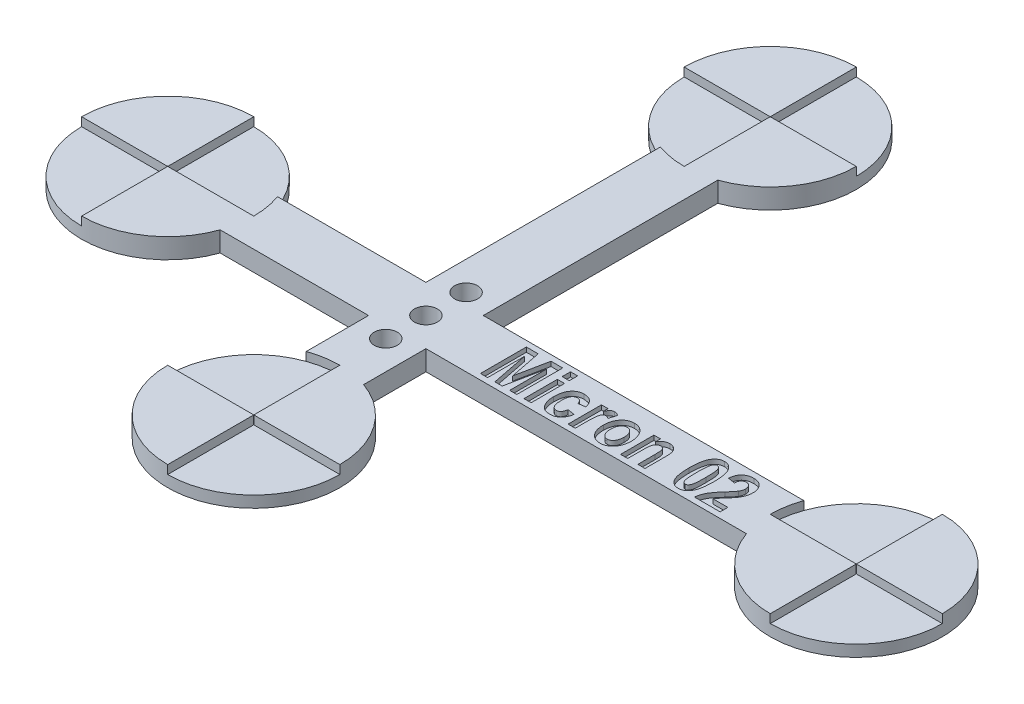
from build123d import *

# Parameters (mm, degrees)
BOSS_EXTRUDE1_DEPTH = 3.5
CUT_EXTRUDE1_DEPTH  = 1.5
SKETCH3_W           = 1.246753247
SKETCH3_H           = 1.454545455
SKETCH3_H_2         = 5.818181818
CUT_EXTRUDE2_DEPTH  = 0.8
SKETCH4_R           = 2
CUT_EXTRUDE3_DEPTH  = 4.5


with BuildPart() as part:
    # Sketch1 → Boss-Extrude1 (new body)
    with BuildSketch(Plane(origin=(0, 0, 0), x_dir=(1, 0, 0), z_dir=(0, 1, 0))):
        with BuildLine():
            Line((40, 45.857864376), (40, 5))
            Line((40, 5), (14.142135624, 5))
            ThreePointArc((14.142135624, 5), (-15, 0), (14.142135624, -5))
            Line((14.142135624, -5), (40, -5))
            Line((40, -5), (40, -15.857864376))
            ThreePointArc((40, -15.857864376), (45, -45), (50, -15.857864376))
            Line((50, -15.857864376), (50, -5))
            Line((50, -5), (105.857864376, -5))
            ThreePointArc((105.857864376, -5), (135, 0), (105.857864376, 5))
            Line((105.857864376, 5), (50, 5))
            Line((50, 5), (50, 45.857864376))
            ThreePointArc((50, 45.857864376), (45, 75), (40, 45.857864376))
        make_face()
    extrude(amount=BOSS_EXTRUDE1_DEPTH)

    # Sketch2 → Cut-Extrude1 (cut)
    with BuildSketch(Plane(origin=(0, 3.5, 0), x_dir=(1, 0, 0), z_dir=(0, 1, 0))):
        with BuildLine():
            Line((-15, 0), (-0.05, 0))
            ThreePointArc((-0.05, 0), (-0.035355339, 0.035355339), (0, 0.05))
            Line((0, 0.05), (0, 15))
            ThreePointArc((0, 15), (10.606601718, 10.606601718), (15, 0))
            Line((15, 0), (0.05, 0))
            ThreePointArc((0.05, 0), (0.035355339, -0.035355339), (0, -0.05))
            Line((0, -0.05), (0, -15))
            ThreePointArc((0, -15), (-10.606601718, -10.606601718), (-15, 0))
        make_face()
        with BuildLine():
            Line((45, 75), (45, 60.05))
            ThreePointArc((45, 60.05), (44.964644661, 60.035355339), (44.95, 60))
            Line((44.95, 60), (30, 60))
            ThreePointArc((30, 60), (34.393398282, 49.393398282), (45, 45))
            Line((45, 45), (45, 59.95))
            ThreePointArc((45, 59.95), (45.035355339, 59.964644661), (45.05, 60))
            Line((45.05, 60), (60, 60))
            ThreePointArc((60, 60), (55.606601718, 70.606601718), (45, 75))
        make_face()
        with BuildLine():
            Line((120, 15), (120, 0.05))
            ThreePointArc((120, 0.05), (120.035355339, 0.035355339), (120.05, 0))
            Line((120.05, 0), (135, 0))
            ThreePointArc((135, 0), (130.606601718, -10.606601718), (120, -15))
            Line((120, -15), (120, -0.05))
            ThreePointArc((120, -0.05), (119.964644661, -0.035355339), (119.95, 0))
            Line((119.95, 0), (105, 0))
            ThreePointArc((105, 0), (109.393398282, 10.606601718), (120, 15))
        make_face()
        with BuildLine():
            Line((30, -30), (44.95, -30))
            ThreePointArc((44.95, -30), (44.964644661, -30.035355339), (45, -30.05))
            Line((45, -30.05), (45, -45))
            ThreePointArc((45, -45), (55.606601718, -40.606601718), (60, -30))
            Line((60, -30), (45.05, -30))
            ThreePointArc((45.05, -30), (45.035355339, -29.964644661), (45, -29.95))
            Line((45, -29.95), (45, -15))
            ThreePointArc((45, -15), (34.393398282, -19.393398282), (30, -30))
        make_face()
    extrude(amount=-CUT_EXTRUDE1_DEPTH, mode=Mode.SUBTRACT)

    # Sketch3 → Cut-Extrude2 (cut)
    with BuildSketch(Plane(origin=(0, 3.5, 0), x_dir=(1, 0, 0), z_dir=(0, 1, 0))):
        Polygon((58.50036076, -4), (58.50036076, 4), (60.563672448, 4), (61.669191928, -1.561688312), (62.795815305, 4), (64.838023097, 4), (64.838023097, -4), (63.59126985, -4), (63.59126985, 2.400974026), (62.290945175, -4), (61.023088032, -4), (59.747114006, 2.400974026), (59.747114006, -4), align=None)
        with Locations((66.708152968, 3.376623377)):
            Rectangle(SKETCH3_W, SKETCH3_H)
        with Locations((66.708152968, -1.090909091)):
            Rectangle(SKETCH3_W, SKETCH3_H_2)
        with BuildLine():
            Line((72.734126993, 0.155844156), (71.487373747, -0.051948052))
            add(Edge.make_bspline(
                [(71.487373747, -0.051948052), (71.475238631, 0.013492139), (71.452160271, 0.137945199), (71.389179941, 0.307989308), (71.312160634, 0.454611766), (71.213055442, 0.573886506), (71.095416345, 0.667213464), (70.958609537, 0.733166985), (70.803936467, 0.772456922), (70.694860886, 0.776912369), (70.638347773, 0.779220779)],
                knots=[0, 0, 0, 0, 0.000199325, 0.000379073, 0.0005418, 0.000693948, 0.000840745, 0.000988855, 0.001146348, 0.001315678, 0.001315678, 0.001315678, 0.001315678], degree=3))
            add(Edge.make_bspline(
                [(70.638347773, 0.779220779), (70.600905429, 0.778062939), (70.527122523, 0.775781331), (70.420010496, 0.755102855), (70.317553938, 0.725549098), (70.222958212, 0.677663569), (70.130758823, 0.622007918), (70.046957124, 0.549315551), (69.968136169, 0.465515202), (69.894709448, 0.369037743), (69.827095322, 0.257785931), (69.770603047, 0.128257783), (69.725083376, -0.018687378), (69.68335517, -0.181979253), (69.653655963, -0.363419746), (69.633180941, -0.562384664), (69.620101663, -0.77850796), (69.618220871, -0.928551854), (69.617243876, -1.006493506)],
                knots=[0, 0, 0, 0, 0.000112201, 0.0002211, 0.00032637, 0.000430923, 0.000538128, 0.000648708, 0.000762403, 0.000882861, 0.001011764, 0.001152033, 0.001305535, 0.001472868, 0.001657284, 0.001856457, 0.002072757, 0.002306574, 0.002306574, 0.002306574, 0.002306574], degree=3))
            add(Edge.make_bspline(
                [(69.617243876, -1.006493506), (69.618261217, -1.092546265), (69.620213954, -1.257720471), (69.632711779, -1.496116795), (69.65538517, -1.714396148), (69.685469478, -1.914085761), (69.725675307, -2.093641007), (69.774055334, -2.254680712), (69.831596703, -2.395907747), (69.899086485, -2.518208897), (69.974173657, -2.623094471), (70.056196277, -2.712538943), (70.142228328, -2.791034021), (70.2374127, -2.851962864), (70.336627186, -2.901864568), (70.442857496, -2.935934853), (70.55464497, -2.95784839), (70.631749283, -2.959966029), (70.670815305, -2.961038961)],
                knots=[0, 0, 0, 0, 0.000258163, 0.000495531, 0.000715862, 0.000916302, 0.00110101, 0.001267389, 0.001420236, 0.001557572, 0.001685521, 0.001806187, 0.001921184, 0.002033748, 0.002144102, 0.002253448, 0.002367432, 0.002484495, 0.002484495, 0.002484495, 0.002484495], degree=3))
            add(Edge.make_bspline(
                [(70.670815305, -2.961038961), (70.72855094, -2.958115137), (70.840148837, -2.952463643), (70.998917272, -2.902884688), (71.141871425, -2.82385793), (71.244914469, -2.730611667), (71.318466989, -2.639969699), (71.370108431, -2.557981246), (71.418545215, -2.464077917), (71.462084604, -2.358060987), (71.501266248, -2.240396767), (71.534349316, -2.110465037), (71.565645908, -1.968673701), (71.582502685, -1.869672225), (71.59126985, -1.818181818)],
                knots=[0, 0, 0, 0, 0.000172842, 0.000334088, 0.000493972, 0.000659525, 0.000747247, 0.000843616, 0.000949622, 0.001063883, 0.001187088, 0.001321358, 0.001465921, 0.001622591, 0.001622591, 0.001622591, 0.001622591], degree=3))
            Line((71.59126985, -1.818181818), (72.838023097, -2.025974026))
            add(Edge.make_bspline(
                [(72.838023097, -2.025974026), (72.821015846, -2.110033143), (72.787894315, -2.273737832), (72.725282574, -2.51019173), (72.648292222, -2.729306841), (72.562922764, -2.933353422), (72.465367894, -3.120817392), (72.35648555, -3.292169834), (72.236010198, -3.447294215), (72.103969601, -3.586117196), (71.960430352, -3.708703947), (71.805564143, -3.814231607), (71.640086257, -3.904896068), (71.462835354, -3.977226655), (71.274845438, -4.034537616), (71.075882267, -4.074640125), (70.865713047, -4.099528833), (70.721752457, -4.102417816), (70.648088032, -4.103896104)],
                knots=[0, 0, 0, 0, 0.000257263, 0.000501018, 0.000733076, 0.000953485, 0.001164055, 0.001366255, 0.001561742, 0.001752349, 0.001940051, 0.002126916, 0.002313611, 0.002505046, 0.002700189, 0.002902356, 0.003113183, 0.003334111, 0.003334111, 0.003334111, 0.003334111], degree=3))
            add(Edge.make_bspline(
                [(70.648088032, -4.103896104), (70.554819841, -4.101887492), (70.37321271, -4.097976423), (70.110471697, -4.053593587), (69.864673186, -3.987367001), (69.639207309, -3.888476021), (69.431834059, -3.764176577), (69.243759839, -3.611361294), (69.073517705, -3.431602628), (68.925921273, -3.224317401), (68.795814013, -2.999463478), (68.681997355, -2.762165056), (68.585965745, -2.513438303), (68.506034653, -2.254410985), (68.446476255, -1.98270864), (68.403410095, -1.700737492), (68.374039392, -1.407542533), (68.371686907, -1.208406699), (68.37049063, -1.107142857)],
                knots=[0, 0, 0, 0, 0.000279523, 0.000544272, 0.000797144, 0.001041429, 0.001280302, 0.001520398, 0.001766145, 0.002020725, 0.002281892, 0.002544739, 0.002809429, 0.003081077, 0.00335717, 0.003643018, 0.003936526, 0.004240206, 0.004240206, 0.004240206, 0.004240206], degree=3))
            add(Edge.make_bspline(
                [(68.37049063, -1.107142857), (68.372239743, -0.987488549), (68.375640625, -0.75483916), (68.405336818, -0.417027711), (68.452726945, -0.100401237), (68.522926455, 0.193547978), (68.609847208, 0.466113039), (68.716501303, 0.716580192), (68.846096582, 0.943069469), (68.991820845, 1.149170928), (69.156114523, 1.330213011), (69.331961705, 1.489088097), (69.520060194, 1.623763244), (69.721234776, 1.733258723), (69.935011157, 1.818073271), (70.160732658, 1.877319248), (70.397782122, 1.916873853), (70.560259998, 1.920318934), (70.643217902, 1.922077922)],
                knots=[0, 0, 0, 0, 0.000358898, 0.000697823, 0.001016501, 0.00131851, 0.001603435, 0.001873935, 0.002133483, 0.002384849, 0.002629678, 0.002865336, 0.003094623, 0.003322001, 0.003550805, 0.003782743, 0.004021075, 0.004269712, 0.004269712, 0.004269712, 0.004269712], degree=3))
            add(Edge.make_bspline(
                [(70.643217902, 1.922077922), (70.71035858, 1.920846466), (70.841687336, 1.918437708), (71.034520622, 1.899106266), (71.217142954, 1.864581364), (71.391368457, 1.819675788), (71.554972261, 1.759740953), (71.709026878, 1.685791916), (71.853826329, 1.599814288), (71.98980103, 1.500415487), (72.115185036, 1.385394066), (72.233134509, 1.256930605), (72.340019014, 1.110862201), (72.439342218, 0.950708523), (72.526615855, 0.773374249), (72.606095879, 0.582082787), (72.676087051, 0.374743093), (72.714406275, 0.230221286), (72.734126993, 0.155844156)],
                knots=[0, 0, 0, 0, 0.000201403, 0.00039395, 0.000580532, 0.000758512, 0.000933129, 0.001102311, 0.00127047, 0.001437685, 0.001606618, 0.001780137, 0.00196001, 0.002148783, 0.002344802, 0.00255222, 0.002769885, 0.003000685, 0.003000685, 0.003000685, 0.003000685], degree=3))
        make_face()
        with BuildLine():
            Line((75.019841279, -4), (73.773088032, -4))
            Line((73.773088032, -4), (73.773088032, 1.818181818))
            Line((73.773088032, 1.818181818), (74.915945175, 1.818181818))
            Line((74.915945175, 1.818181818), (74.915945175, 0.991883117))
            add(Edge.make_bspline(
                [(74.915945175, 0.991883117), (74.940159399, 1.037952881), (74.986797897, 1.126686869), (75.05617644, 1.253336089), (75.123683954, 1.367923953), (75.192594719, 1.467096929), (75.254997633, 1.556811947), (75.319023898, 1.631359029), (75.379881779, 1.694731582), (75.457465413, 1.762170073), (75.560087337, 1.826053482), (75.691232303, 1.882473547), (75.832643067, 1.915363311), (75.929848968, 1.919815142), (75.979256863, 1.922077922)],
                knots=[0, 0, 0, 0, 0.000156131, 0.000300721, 0.000433243, 0.000554812, 0.000662946, 0.000760848, 0.000849244, 0.000926367, 0.001068679, 0.001209792, 0.001353128, 0.001501291, 0.001501291, 0.001501291, 0.001501291], degree=3))
            add(Edge.make_bspline(
                [(75.979256863, 1.922077922), (76.049468143, 1.91886318), (76.189930484, 1.912431875), (76.396264458, 1.852623193), (76.598585759, 1.762131289), (76.72239596, 1.675863479), (76.786075045, 1.631493506)],
                knots=[0, 0, 0, 0, 0.000210176, 0.00042047, 0.000639866, 0.000872208, 0.000872208, 0.000872208, 0.000872208], degree=3))
            Line((76.786075045, 1.631493506), (76.391594526, 0.319805195))
            add(Edge.make_bspline(
                [(76.391594526, 0.319805195), (76.343457298, 0.358255441), (76.252471756, 0.430931343), (76.106176233, 0.509110372), (75.96429064, 0.560954838), (75.869258342, 0.568020125), (75.823412708, 0.571428571)],
                knots=[0, 0, 0, 0, 0.000184416, 0.00034857, 0.000495904, 0.00063323, 0.00063323, 0.00063323, 0.00063323], degree=3))
            add(Edge.make_bspline(
                [(75.823412708, 0.571428571), (75.782505012, 0.569577552), (75.701066257, 0.565892554), (75.584319511, 0.525699903), (75.474380215, 0.46484784), (75.373247856, 0.375884101), (75.28120342, 0.255501948), (75.208770468, 0.094601523), (75.146148418, -0.102439271), (75.107437305, -0.295455124), (75.083085691, -0.477538767), (75.06505598, -0.645297865), (75.050951083, -0.839680763), (75.040281294, -1.060551746), (75.030100881, -1.307830134), (75.023930168, -1.582222395), (75.021131213, -1.883652001), (75.020282911, -2.093614232), (75.019841279, -2.202922078)],
                knots=[0, 0, 0, 0, 0.000122282, 0.000243439, 0.00036627, 0.000497452, 0.000644536, 0.000817347, 0.001023727, 0.001264102, 0.001406673, 0.001574831, 0.001770184, 0.001991255, 0.002238201, 0.002512628, 0.002814594, 0.00314252, 0.00314252, 0.00314252, 0.00314252], degree=3))
            Line((75.019841279, -2.202922078), (75.019841279, -4))
        make_face()
        with BuildLine():
            add(Edge.make_bspline(
                [(76.993867253, -1.00974026), (76.99773938, -0.871492577), (77.005358765, -0.599455473), (77.07087566, -0.202105645), (77.173904845, 0.177168447), (77.298261932, 0.475142281), (77.414852128, 0.700213025), (77.508933594, 0.858166819), (77.610211845, 1.0047968), (77.716400181, 1.140905493), (77.830224235, 1.265802708), (77.948905998, 1.380456268), (78.075551332, 1.483975824), (78.251872281, 1.606243165), (78.48640792, 1.734106031), (78.786697572, 1.843482079), (79.103960535, 1.910979968), (79.321452502, 1.918333961), (79.432178941, 1.922077922)],
                knots=[0, 0, 0, 0, 0.000414499, 0.00081563, 0.001204757, 0.001591247, 0.00178148, 0.00196495, 0.002142367, 0.002315787, 0.002482426, 0.002648908, 0.002810415, 0.002972534, 0.003292157, 0.00360852, 0.00392849, 0.004260331, 0.004260331, 0.004260331, 0.004260331], degree=3))
            add(Edge.make_bspline(
                [(79.432178941, 1.922077922), (79.524844362, 1.919080026), (79.706214487, 1.913212371), (79.970819979, 1.872921067), (80.219608224, 1.802229151), (80.453953528, 1.705294578), (80.670723745, 1.576365199), (80.874437856, 1.423442467), (81.059923504, 1.239208288), (81.228428557, 1.030627633), (81.37997441, 0.803981072), (81.513296238, 0.565748818), (81.625008798, 0.317712454), (81.719657136, 0.061815795), (81.787549524, -0.205805812), (81.840332848, -0.481537671), (81.871889339, -0.767122546), (81.87526987, -0.960420315), (81.876984136, -1.058441558)],
                knots=[0, 0, 0, 0, 0.000277982, 0.000544082, 0.000800519, 0.001052268, 0.001302568, 0.001555169, 0.001814604, 0.002084622, 0.002358372, 0.002631625, 0.002902613, 0.00317376, 0.003448993, 0.003729814, 0.004015574, 0.004309567, 0.004309567, 0.004309567, 0.004309567], degree=3))
            add(Edge.make_bspline(
                [(81.876984136, -1.058441558), (81.876227692, -1.131529258), (81.874729677, -1.276267575), (81.857345801, -1.490737935), (81.832372892, -1.700083082), (81.794451847, -1.904353031), (81.74632035, -2.102762528), (81.686787225, -2.295895078), (81.619804227, -2.484139081), (81.53955722, -2.665021822), (81.453170655, -2.838694854), (81.356567034, -3.000287959), (81.256676902, -3.152976813), (81.14667086, -3.291813358), (81.033747016, -3.423233057), (80.911462009, -3.541439921), (80.783056626, -3.649149424), (80.604551972, -3.775655653), (80.369934842, -3.906802618), (80.071483883, -4.020332864), (79.759616253, -4.091116904), (79.546182896, -4.0996153), (79.438672448, -4.103896104)],
                knots=[0, 0, 0, 0, 0.00021921, 0.00043411, 0.00064513, 0.000851458, 0.001056987, 0.001257262, 0.001457537, 0.001655994, 0.001850563, 0.002039049, 0.002220497, 0.002397475, 0.002570043, 0.002739947, 0.002907061, 0.003072374, 0.003395769, 0.003710226, 0.004027699, 0.00434993, 0.00434993, 0.00434993, 0.00434993], degree=3))
            add(Edge.make_bspline(
                [(79.438672448, -4.103896104), (79.352502729, -4.101341217), (79.183124459, -4.096319241), (78.934716636, -4.058456248), (78.698054839, -3.99479852), (78.472549003, -3.90676201), (78.258016744, -3.793542556), (78.054181778, -3.655526311), (77.864029071, -3.488983811), (77.683779026, -3.302138577), (77.520670531, -3.090331966), (77.380150134, -2.855461331), (77.258457363, -2.600481865), (77.162310721, -2.322961565), (77.085543251, -2.024985427), (77.033233234, -1.70496049), (77.000302919, -1.364326972), (76.996049016, -1.12994916), (76.993867253, -1.00974026)],
                knots=[0, 0, 0, 0, 0.000258443, 0.000508006, 0.000751761, 0.000992327, 0.001232686, 0.001478079, 0.001728994, 0.001989631, 0.002255885, 0.002529003, 0.002809298, 0.003101956, 0.003408675, 0.003731336, 0.004073787, 0.004434356, 0.004434356, 0.004434356, 0.004434356], degree=3))
        make_face()
        with BuildLine():
            add(Edge.make_bspline(
                [(78.2406205, -1.090909091), (78.241193573, -1.161301131), (78.242306492, -1.298003716), (78.261234707, -1.496347271), (78.288602558, -1.681695553), (78.324236438, -1.854514739), (78.376162408, -2.012893615), (78.434745234, -2.159458772), (78.506897923, -2.292206203), (78.589461187, -2.410648066), (78.680939517, -2.51464094), (78.776964817, -2.605361366), (78.875632321, -2.685555047), (78.982414792, -2.746314388), (79.091993225, -2.7960892), (79.205812587, -2.83181335), (79.324708332, -2.854023891), (79.405564639, -2.856089635), (79.446789331, -2.857142857)],
                knots=[0, 0, 0, 0, 0.000211095, 0.000409951, 0.000597062, 0.000773144, 0.000938458, 0.001096426, 0.001246068, 0.00139063, 0.001528684, 0.001660738, 0.001786746, 0.001908974, 0.002028146, 0.002147262, 0.002266036, 0.002389583, 0.002389583, 0.002389583, 0.002389583], degree=3))
            add(Edge.make_bspline(
                [(79.446789331, -2.857142857), (79.486930477, -2.856062286), (79.566168615, -2.853929251), (79.682924616, -2.831796204), (79.794636913, -2.796265769), (79.902095046, -2.746661195), (80.004819397, -2.682536946), (80.103605063, -2.604942025), (80.196824143, -2.512150646), (80.285902055, -2.407554507), (80.367452538, -2.288190002), (80.439332996, -2.15529938), (80.496230932, -2.007207398), (80.548090785, -1.84851973), (80.583928744, -1.674677795), (80.611733592, -1.488309881), (80.627963108, -1.288165559), (80.629460002, -1.150461681), (80.630230889, -1.079545455)],
                knots=[0, 0, 0, 0, 0.000120305, 0.000237481, 0.00035505, 0.000471266, 0.000591549, 0.000717557, 0.000847275, 0.000985501, 0.00112914, 0.00128021, 0.001437568, 0.001604429, 0.001780511, 0.001969228, 0.002169562, 0.00238228, 0.00238228, 0.00238228, 0.00238228], degree=3))
            add(Edge.make_bspline(
                [(80.630230889, -1.079545455), (80.629657673, -1.010234819), (80.628544962, -0.875690947), (80.609642621, -0.680588811), (80.582133444, -0.497953131), (80.546465486, -0.327351399), (80.49521573, -0.170068224), (80.433692654, -0.025632812), (80.362554163, 0.1072581), (80.279265313, 0.225728002), (80.188791642, 0.330494971), (80.093903874, 0.422586459), (79.99490702, 0.50126615), (79.890651683, 0.564846212), (79.782053107, 0.614109415), (79.669460084, 0.65026489), (79.551531628, 0.672061169), (79.471231571, 0.67422738), (79.430555565, 0.675324675)],
                knots=[0, 0, 0, 0, 0.000207849, 0.000403471, 0.000587372, 0.000761868, 0.000925636, 0.001082735, 0.001232376, 0.001376939, 0.001516219, 0.001647099, 0.001773107, 0.001894774, 0.002012466, 0.002130035, 0.002248808, 0.002370734, 0.002370734, 0.002370734, 0.002370734], degree=3))
            add(Edge.make_bspline(
                [(79.430555565, 0.675324675), (79.390416835, 0.674238638), (79.311183466, 0.672094813), (79.194392368, 0.650041164), (79.082343389, 0.614060182), (78.973968514, 0.565297339), (78.870848855, 0.500737434), (78.772125734, 0.422584114), (78.677081903, 0.331022603), (78.588667404, 0.225050714), (78.504100416, 0.107532851), (78.436606876, -0.027537366), (78.372844625, -0.171655992), (78.32568136, -0.331268167), (78.285792867, -0.502358852), (78.261951191, -0.687847561), (78.242143614, -0.884859588), (78.241136929, -1.021045607), (78.2406205, -1.090909091)],
                knots=[0, 0, 0, 0, 0.000120305, 0.000237481, 0.00035505, 0.000472742, 0.000593025, 0.000719033, 0.000849914, 0.000988139, 0.001132702, 0.001283011, 0.00144011, 0.001604937, 0.00178137, 0.001966642, 0.002165497, 0.002374969, 0.002374969, 0.002374969, 0.002374969], degree=3))
        make_face(mode=Mode.SUBTRACT)
        with BuildLine():
            Line((87.175685435, -4), (85.928932188, -4))
            Line((85.928932188, -4), (85.928932188, -1.025974026))
            add(Edge.make_bspline(
                [(85.928932188, -1.025974026), (85.92854282, -0.954543529), (85.927799442, -0.818169062), (85.924356954, -0.622819841), (85.920247564, -0.445806445), (85.911867341, -0.287253276), (85.902241106, -0.147618119), (85.891650159, -0.026736408), (85.87710847, 0.075056785), (85.856368171, 0.184335425), (85.821004006, 0.301543782), (85.764596313, 0.426141455), (85.692774231, 0.534382367), (85.604019629, 0.62160385), (85.506619056, 0.69206755), (85.401915582, 0.743240838), (85.289966246, 0.77397023), (85.213215912, 0.777447079), (85.174062058, 0.779220779)],
                knots=[0, 0, 0, 0, 0.000214292, 0.000409124, 0.000586139, 0.000745437, 0.000885387, 0.001006053, 0.001109364, 0.001193733, 0.001339584, 0.001475415, 0.001602837, 0.00172681, 0.001846644, 0.001962086, 0.002074709, 0.002191998, 0.002191998, 0.002191998, 0.002191998], degree=3))
            add(Edge.make_bspline(
                [(85.174062058, 0.779220779), (85.123447016, 0.776869331), (85.023371597, 0.772220076), (84.878191919, 0.730407315), (84.739286208, 0.667322233), (84.612395844, 0.575023409), (84.495650377, 0.46328544), (84.398737064, 0.328262501), (84.317469986, 0.175298829), (84.268630692, 0.030618942), (84.236032455, -0.101357957), (84.218310317, -0.222713773), (84.199402097, -0.363228665), (84.188161741, -0.524290952), (84.175994029, -0.704955422), (84.168471275, -0.905793407), (84.163505023, -1.126597226), (84.162974738, -1.280299629), (84.162698422, -1.36038961)],
                knots=[0, 0, 0, 0, 0.000151532, 0.000299606, 0.000449951, 0.00060715, 0.000767873, 0.000932819, 0.001103467, 0.001285727, 0.00138928, 0.001510979, 0.001653337, 0.001814575, 0.001995128, 0.00219659, 0.002417423, 0.002657688, 0.002657688, 0.002657688, 0.002657688], degree=3))
            Line((84.162698422, -1.36038961), (84.162698422, -4))
            Line((84.162698422, -4), (82.915945175, -4))
            Line((82.915945175, -4), (82.915945175, 1.818181818))
            Line((82.915945175, 1.818181818), (84.058802318, 1.818181818))
            Line((84.058802318, 1.818181818), (84.058802318, 0.965909091))
            add(Edge.make_bspline(
                [(84.058802318, 0.965909091), (84.109710936, 1.041759386), (84.208544913, 1.189015129), (84.378208436, 1.383777654), (84.556148861, 1.549983921), (84.743871586, 1.687067674), (84.943914365, 1.791672469), (85.153616398, 1.866743358), (85.373756253, 1.914536504), (85.524465529, 1.919537791), (85.60101011, 1.922077922)],
                knots=[0, 0, 0, 0, 0.000273831, 0.000531616, 0.00077285, 0.001003084, 0.001226733, 0.001447536, 0.001669767, 0.001899129, 0.001899129, 0.001899129, 0.001899129], degree=3))
            add(Edge.make_bspline(
                [(85.60101011, 1.922077922), (85.688429859, 1.918919658), (85.857463892, 1.912812868), (86.100755155, 1.857826735), (86.32221213, 1.766788484), (86.519497148, 1.639484009), (86.693501252, 1.488180451), (86.837925118, 1.311212589), (86.955005756, 1.115344188), (87.024073318, 0.933951844), (87.069245622, 0.777526046), (87.097815568, 0.646198938), (87.122467785, 0.502145243), (87.140849457, 0.345447453), (87.157608055, 0.176651439), (87.168642166, -0.004744055), (87.17517168, -0.198542646), (87.175511007, -0.332245522), (87.175685435, -0.400974026)],
                knots=[0, 0, 0, 0, 0.000261973, 0.000506549, 0.000743812, 0.00097664, 0.00120785, 0.001432751, 0.0016591, 0.001889414, 0.002012726, 0.002147427, 0.002292345, 0.002451013, 0.002620623, 0.002801175, 0.002996089, 0.003202264, 0.003202264, 0.003202264, 0.003202264], degree=3))
            Line((87.175685435, -0.400974026), (87.175685435, -4))
        make_face()
        with BuildLine():
            add(Edge.make_bspline(
                [(93.042568552, 4), (93.120143484, 3.997148674), (93.273215628, 3.991522391), (93.496552113, 3.948267667), (93.709167709, 3.877994443), (93.909593475, 3.778303449), (94.097951861, 3.649902676), (94.274716094, 3.493575316), (94.44002471, 3.309388361), (94.594940829, 3.095688722), (94.734153575, 2.845756266), (94.853050654, 2.555093261), (94.952904602, 2.222696136), (95.034271056, 1.848605187), (95.098816614, 1.432288922), (95.142527697, 0.973709188), (95.170357365, 0.473287901), (95.173862882, 0.125581293), (95.175685435, -0.055194805)],
                knots=[0, 0, 0, 0, 0.000232602, 0.000458974, 0.000679718, 0.0009026, 0.001128179, 0.00136168, 0.001608802, 0.001869231, 0.002151946, 0.002464883, 0.002809456, 0.003191901, 0.003612528, 0.004072572, 0.004573333, 0.005115628, 0.005115628, 0.005115628, 0.005115628], degree=3))
            add(Edge.make_bspline(
                [(95.175685435, -0.055194805), (95.173858892, -0.235429027), (95.170346113, -0.582052681), (95.14257855, -1.080864069), (95.098621978, -1.538317484), (95.034600767, -1.953666632), (94.952257764, -2.327486698), (94.853811541, -2.659813141), (94.733670888, -2.949980575), (94.595090938, -3.199694145), (94.439887399, -3.412685451), (94.276378827, -3.597979093), (94.099525864, -3.753792128), (93.911527253, -3.881710441), (93.71208139, -3.98233668), (93.500748445, -4.05159659), (93.278700656, -4.095734493), (93.126655602, -4.101138343), (93.049062058, -4.103896104)],
                knots=[0, 0, 0, 0, 0.000540672, 0.001039812, 0.00149824, 0.001918867, 0.002299728, 0.002645854, 0.002957293, 0.003240007, 0.003500437, 0.003746473, 0.003979974, 0.004205554, 0.004426982, 0.004647726, 0.004870909, 0.005103511, 0.005103511, 0.005103511, 0.005103511], degree=3))
            add(Edge.make_bspline(
                [(93.049062058, -4.103896104), (92.971520172, -4.100862637), (92.818612265, -4.094880825), (92.59489671, -4.054282938), (92.382435066, -3.983452229), (92.182511086, -3.883672907), (91.993665393, -3.757214281), (91.816991446, -3.602360262), (91.651459776, -3.419950023), (91.525616278, -3.246353686), (91.430990718, -3.092878847), (91.364980322, -2.964508803), (91.303455869, -2.825479381), (91.244235797, -2.676576112), (91.19349064, -2.514885831), (91.144536647, -2.343474895), (91.100591604, -2.160968409), (91.062673394, -1.967931987), (91.02559404, -1.76477297), (90.998032431, -1.550003327), (90.97076078, -1.325090023), (90.952664467, -1.088321983), (90.93572137, -0.841612758), (90.925283351, -0.583390093), (90.915909942, -0.315001944), (90.915933294, -0.132043959), (90.915945175, -0.038961039)],
                knots=[0, 0, 0, 0, 0.000232602, 0.000458677, 0.000679421, 0.000902303, 0.001126975, 0.001359407, 0.001605326, 0.001864441, 0.002001422, 0.002145912, 0.00229706, 0.002457438, 0.002626339, 0.002805176, 0.002992203, 0.003189274, 0.003395315, 0.003611584, 0.003838724, 0.004074918, 0.004323825, 0.00458057, 0.004850172, 0.005129398, 0.005129398, 0.005129398, 0.005129398], degree=3))
            add(Edge.make_bspline(
                [(90.915945175, -0.038961039), (90.917766425, 0.140733062), (90.92126861, 0.486277146), (90.949096706, 0.983455445), (90.992786068, 1.438795514), (91.057455354, 1.852398974), (91.139031184, 2.224773358), (91.238156972, 2.556355193), (91.357927524, 2.84609395), (91.496547236, 3.095795814), (91.651741372, 3.308789888), (91.815252237, 3.494082856), (91.992104631, 3.649896058), (92.180103387, 3.777814329), (92.379549212, 3.878440579), (92.590882167, 3.947700486), (92.812929954, 3.99183839), (92.964975007, 3.997242239), (93.042568552, 4)],
                knots=[0, 0, 0, 0, 0.000539049, 0.001036568, 0.001493381, 0.0019108, 0.002291661, 0.002636234, 0.002947673, 0.003230387, 0.003490817, 0.003736853, 0.003970355, 0.004195934, 0.004417363, 0.004638106, 0.004861289, 0.005093891, 0.005093891, 0.005093891, 0.005093891], degree=3))
        make_face()
        with BuildLine():
            add(Edge.make_bspline(
                [(93.045815305, 2.753246753), (93.016983802, 2.751588419), (92.959509622, 2.748282613), (92.875927262, 2.724571332), (92.79639698, 2.686845816), (92.722427151, 2.631936572), (92.654531179, 2.560572149), (92.589331771, 2.475933398), (92.529382821, 2.37557449), (92.471821912, 2.257031527), (92.422907436, 2.108173752), (92.379831447, 1.922528032), (92.345944957, 1.69496366), (92.317590249, 1.425720345), (92.292957589, 1.115056325), (92.278036586, 0.762026881), (92.268158161, 0.367481909), (92.267133043, 0.090375275), (92.266594526, -0.055194805)],
                knots=[0, 0, 0, 0, 8.6421e-05, 0.000172276, 0.000258682, 0.000349271, 0.00044685, 0.000553351, 0.00066917, 0.000796964, 0.000947894, 0.001138079, 0.00136814, 0.001637587, 0.001950225, 0.002302871, 0.002697472, 0.003134172, 0.003134172, 0.003134172, 0.003134172], degree=3))
            add(Edge.make_bspline(
                [(92.266594526, -0.055194805), (92.267123328, -0.200765322), (92.268127989, -0.477331814), (92.278100069, -0.871330634), (92.29283468, -1.223292397), (92.317841907, -1.533920343), (92.34564763, -1.80268425), (92.37998794, -2.030198873), (92.42300039, -2.215269381), (92.471382223, -2.36384325), (92.52979398, -2.481451586), (92.589390764, -2.581371854), (92.653964499, -2.666118067), (92.722995564, -2.735808707), (92.79633331, -2.790804977), (92.875943778, -2.828451078), (92.959505472, -2.852182826), (93.016982415, -2.855485896), (93.045815305, -2.857142857)],
                knots=[0, 0, 0, 0, 0.0004367, 0.000829678, 0.001182325, 0.001493344, 0.001764405, 0.001992863, 0.002183047, 0.002333978, 0.002460309, 0.002576128, 0.002682629, 0.002779053, 0.002869643, 0.002956049, 0.003041904, 0.003128325, 0.003128325, 0.003128325, 0.003128325], degree=3))
            add(Edge.make_bspline(
                [(93.045815305, -2.857142857), (93.075188368, -2.85552029), (93.133206372, -2.852315378), (93.21738504, -2.828542533), (93.297029049, -2.790253808), (93.372435814, -2.736496976), (93.439646108, -2.664443264), (93.506337432, -2.581825172), (93.563423586, -2.480471516), (93.621525538, -2.362653873), (93.670754282, -2.213878514), (93.710709098, -2.027621166), (93.748134759, -1.800724279), (93.775757394, -1.53179805), (93.798173843, -1.221589379), (93.813727392, -0.869719468), (93.823431124, -0.476245826), (93.824483267, -0.20022291), (93.825036084, -0.055194805)],
                knots=[0, 0, 0, 0, 8.8037e-05, 0.000173892, 0.000260298, 0.000352202, 0.00044978, 0.000554999, 0.000669985, 0.000797778, 0.000948709, 0.001138526, 0.001368845, 0.001638291, 0.001949188, 0.002301835, 0.002694813, 0.00312989, 0.00312989, 0.00312989, 0.00312989], degree=3))
            add(Edge.make_bspline(
                [(93.825036084, -0.055194805), (93.824478904, 0.090374192), (93.823418258, 0.367478764), (93.813778191, 0.762037569), (93.798092676, 1.114981824), (93.775844364, 1.425743409), (93.748129467, 1.695205512), (93.710705916, 1.922098251), (93.670766677, 2.108368799), (93.621491087, 2.257107732), (93.563526869, 2.37503186), (93.505793041, 2.476420917), (93.440190416, 2.560429298), (93.372374904, 2.632553578), (93.297043894, 2.68636923), (93.217381216, 2.724643459), (93.133207354, 2.748420037), (93.075188698, 2.751624443), (93.045815305, 2.753246753)],
                knots=[0, 0, 0, 0, 0.0004367, 0.000831301, 0.001183948, 0.001496464, 0.00176591, 0.001996229, 0.002186046, 0.002336977, 0.00246477, 0.002579756, 0.002686257, 0.002783835, 0.002875739, 0.002962145, 0.003048, 0.003136037, 0.003136037, 0.003136037, 0.003136037], degree=3))
        make_face(mode=Mode.SUBTRACT)
        with BuildLine():
            Line((100.266594526, -2.649350649), (100.266594526, -4))
            Line((100.266594526, -4), (95.799062058, -4))
            add(Edge.make_bspline(
                [(95.799062058, -4), (95.81478087, -3.866975025), (95.846175788, -3.601286497), (95.941241091, -3.211335878), (96.069387686, -2.83038878), (96.209708694, -2.520193485), (96.348959735, -2.269734358), (96.473529227, -2.065380087), (96.621877989, -1.847926199), (96.793828749, -1.617667333), (96.984491033, -1.371191394), (97.198081648, -1.111083484), (97.433488219, -0.837114545), (97.599604049, -0.651229808), (97.685425695, -0.555194805)],
                knots=[0, 0, 0, 0, 0.000401539, 0.000801987, 0.001201384, 0.001606051, 0.001821122, 0.002060838, 0.00232379, 0.002610485, 0.002922866, 0.00325856, 0.003620052, 0.004006429, 0.004006429, 0.004006429, 0.004006429], degree=3))
            add(Edge.make_bspline(
                [(97.685425695, -0.555194805), (97.752715446, -0.480145853), (97.881446748, -0.336570508), (98.062518505, -0.128659926), (98.225392008, 0.05830232), (98.364876692, 0.228175889), (98.48588754, 0.377408836), (98.586175814, 0.508276081), (98.666944282, 0.61964315), (98.710115023, 0.689711169), (98.729256863, 0.720779221)],
                knots=[0, 0, 0, 0, 0.000302388, 0.000578496, 0.000827122, 0.0010462, 0.001237868, 0.001403461, 0.001540845, 0.001650287, 0.001650287, 0.001650287, 0.001650287], degree=3))
            add(Edge.make_bspline(
                [(98.729256863, 0.720779221), (98.773682191, 0.800361399), (98.860401412, 0.955707571), (98.950705775, 1.201881109), (99.009732399, 1.448498464), (99.016496545, 1.614395727), (99.019841279, 1.696428571)],
                knots=[0, 0, 0, 0, 0.000273022, 0.000532945, 0.000784212, 0.001029991, 0.001029991, 0.001029991, 0.001029991], degree=3))
            add(Edge.make_bspline(
                [(99.019841279, 1.696428571), (99.016968385, 1.778391919), (99.011529812, 1.933553787), (98.964985078, 2.150341294), (98.88717363, 2.336775565), (98.774704898, 2.488144614), (98.63778432, 2.606963508), (98.479856428, 2.69366854), (98.301120629, 2.74503152), (98.175482475, 2.750453306), (98.11075037, 2.753246753)],
                knots=[0, 0, 0, 0, 0.000245667, 0.000465063, 0.000661384, 0.000847103, 0.001025475, 0.001201288, 0.001383692, 0.001577555, 0.001577555, 0.001577555, 0.001577555], degree=3))
            add(Edge.make_bspline(
                [(98.11075037, 2.753246753), (98.040555229, 2.750179354), (97.906013939, 2.744300146), (97.71678682, 2.689564165), (97.552547412, 2.599335307), (97.417958186, 2.468381301), (97.307497381, 2.304776296), (97.227746931, 2.103668919), (97.173068321, 1.86887964), (97.157807452, 1.699988206), (97.149711409, 1.61038961)],
                knots=[0, 0, 0, 0, 0.000210176, 0.000402838, 0.000585271, 0.000766698, 0.000960758, 0.001173296, 0.00141191, 0.001681537, 0.001681537, 0.001681537, 0.001681537], degree=3))
            Line((97.149711409, 1.61038961), (95.902958162, 1.818181818))
            add(Edge.make_bspline(
                [(95.902958162, 1.818181818), (95.913398012, 1.909319451), (95.933650085, 2.08611567), (95.987276535, 2.340058871), (96.050785718, 2.576100968), (96.130306988, 2.79302039), (96.224609428, 2.99110008), (96.334012548, 3.170121694), (96.455361974, 3.333097595), (96.594781923, 3.47452128), (96.74670903, 3.598248444), (96.910117903, 3.706542682), (97.086211606, 3.797097091), (97.273454201, 3.872609367), (97.473540347, 3.928515141), (97.684434553, 3.971313574), (97.907807069, 3.995453087), (98.060370145, 3.998462061), (98.138347773, 4)],
                knots=[0, 0, 0, 0, 0.000275056, 0.000533576, 0.000777758, 0.001007854, 0.001225683, 0.001434771, 0.001636397, 0.001833849, 0.002028823, 0.00222333, 0.002420823, 0.002621892, 0.002827933, 0.003043152, 0.003266883, 0.00350079, 0.00350079, 0.00350079, 0.00350079], degree=3))
            add(Edge.make_bspline(
                [(98.138347773, 4), (98.223982812, 3.998620901), (98.389967069, 3.995947827), (98.630414543, 3.961259281), (98.855542576, 3.911835408), (99.063136032, 3.834957973), (99.256824338, 3.742481919), (99.430996175, 3.622765337), (99.59279576, 3.487080863), (99.731517276, 3.325997826), (99.857794818, 3.155732301), (99.96621847, 2.976282017), (100.06009584, 2.792410642), (100.134902969, 2.600830042), (100.193141741, 2.403028087), (100.235112285, 2.19942609), (100.262603616, 1.989928758), (100.265250428, 1.848031798), (100.266594526, 1.775974026)],
                knots=[0, 0, 0, 0, 0.000256678, 0.000497513, 0.000727483, 0.000946759, 0.001160207, 0.001369572, 0.001579108, 0.001791844, 0.002005489, 0.002214578, 0.002420036, 0.002624123, 0.002830618, 0.003037883, 0.003247292, 0.003463354, 0.003463354, 0.003463354, 0.003463354], degree=3))
            add(Edge.make_bspline(
                [(100.266594526, 1.775974026), (100.265230409, 1.694185479), (100.262522222, 1.531810401), (100.23470911, 1.290013591), (100.193630316, 1.05158636), (100.13269383, 0.816208048), (100.053896458, 0.582681297), (99.957944771, 0.348984339), (99.844250786, 0.114350153), (99.732293984, -0.080058202), (99.631978599, -0.241569626), (99.542650833, -0.370666959), (99.440848491, -0.507313883), (99.329425747, -0.653809617), (99.204013677, -0.807334269), (99.067670594, -0.969714843), (98.919919771, -1.140188306), (98.816546732, -1.255560809), (98.763347773, -1.314935065)],
                knots=[0, 0, 0, 0, 0.000245264, 0.000486924, 0.000729264, 0.000970624, 0.001215495, 0.001468122, 0.001728045, 0.001997056, 0.002140741, 0.002298342, 0.002467828, 0.002651929, 0.002850446, 0.003062457, 0.003288018, 0.003527179, 0.003527179, 0.003527179, 0.003527179], degree=3))
            add(Edge.make_bspline(
                [(98.763347773, -1.314935065), (98.714087081, -1.369571245), (98.62017075, -1.473736036), (98.486214171, -1.622898939), (98.368942161, -1.759736694), (98.262654799, -1.879269317), (98.171996842, -1.985005839), (98.094657077, -2.075632352), (98.034078034, -2.153817086), (97.942322289, -2.26804534), (97.832127317, -2.428833311), (97.753909532, -2.577709151), (97.71626985, -2.649350649)],
                knots=[0, 0, 0, 0, 0.000220696, 0.00042076, 0.000601422, 0.000761314, 0.000900594, 0.001019278, 0.001118663, 0.001197259, 0.001458869, 0.001701535, 0.001701535, 0.001701535, 0.001701535], degree=3))
            Line((97.71626985, -2.649350649), (100.266594526, -2.649350649))
        make_face()
    extrude(amount=-CUT_EXTRUDE2_DEPTH, mode=Mode.SUBTRACT)

    # Sketch4 → Cut-Extrude3 (cut, through all)
    with BuildSketch(Plane(origin=(0, 3.5, 0), x_dir=(1, 0, 0), z_dir=(0, 1, 0))):
        with Locations((45, 0)):
            Circle(SKETCH4_R)
        with Locations((45, 7)):
            Circle(SKETCH4_R)
        with Locations((45, -7)):
            Circle(SKETCH4_R)
    extrude(amount=-CUT_EXTRUDE3_DEPTH, mode=Mode.SUBTRACT)


solid = part.part
